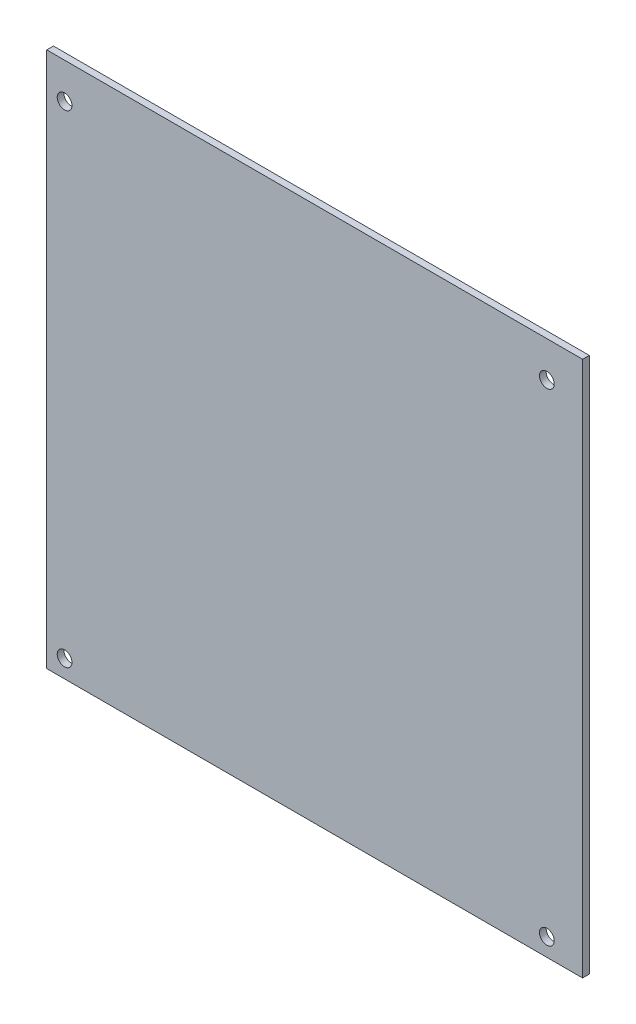
from build123d import *

# Parameters (mm, degrees)
SKETCH_1_W      = 120
SKETCH_1_H      = 120
SKETCH_1_R      = 1.65
EXTRUDE_1_DEPTH = 1.5


with BuildPart() as part:
    # Эскиз1 → Бобышка-Вытянуть1 (new body)
    with BuildSketch(Plane.XY):
        with Locations((60, 60)):
            Rectangle(SKETCH_1_W, SKETCH_1_H)
        with Locations((4, 4)):
            Circle(SKETCH_1_R, mode=Mode.SUBTRACT)
        with Locations((112, 4)):
            Circle(SKETCH_1_R, mode=Mode.SUBTRACT)
        with Locations((4, 112)):
            Circle(SKETCH_1_R, mode=Mode.SUBTRACT)
        with Locations((112, 112)):
            Circle(SKETCH_1_R, mode=Mode.SUBTRACT)
    extrude(amount=EXTRUDE_1_DEPTH)


solid = part.part
